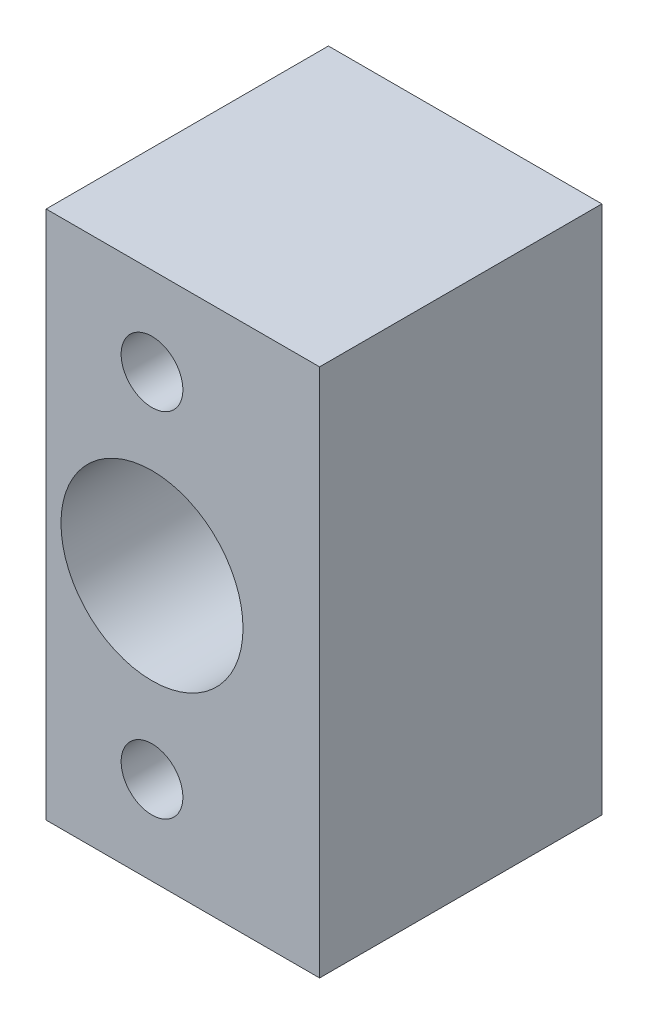
from build123d import *

# Parameters (mm, degrees)
SKETCH1_W               = 19
SKETCH1_H               = 30
BOSS_EXTRUDE1_DEPTH     = 18
SKETCH2_R               = 5.159375
CUT_EXTRUDE1_DEPTH      = 11.5
SKETCH4_R               = 4.8
CUT_EXTRUDE3_DEPTH      = 0.5
CUT_EXTRUDE4_DEPTH      = 22.430118992
CUT_EXTRUDE4_DEPTH_BACK = 8
SKETCH5_R               = 2.38125
CUT_EXTRUDE6_DEPTH      = 26.28339376
CUT_EXTRUDE6_DEPTH_BACK = 26.28339376
SKETCH11_W              = 15.5
SKETCH11_H              = 30
BOSS_EXTRUDE5_DEPTH     = 5
SKETCH12_R              = 4
CUT_EXTRUDE8_DEPTH      = 7.9
SKETCH13_R              = 1.75
CUT_EXTRUDE9_DEPTH      = 30.055980452
SKETCH15_W              = 15.5
SKETCH15_H              = 2
SKETCH15_H_2            = 5
CUT_EXTRUDE11_DEPTH     = 41
SKETCH17_R              = 5
CUT_EXTRUDE12_DEPTH     = 2
SKETCH20_R              = 3.81
CUT_EXTRUDE13_DEPTH     = 4


with BuildPart() as part:
    # Sketch1 → Boss-Extrude1 (new body)
    with BuildSketch(Plane.XY):
        Rectangle(SKETCH1_W, SKETCH1_H)
    extrude(amount=BOSS_EXTRUDE1_DEPTH)

    # Sketch2 → Cut-Extrude1 (cut)
    with BuildSketch(Plane.XY.offset(18)):
        Circle(SKETCH2_R)
    extrude(amount=-CUT_EXTRUDE1_DEPTH, mode=Mode.SUBTRACT)

    # Sketch4 → Cut-Extrude3 (cut)
    with BuildSketch(Plane.XY.offset(6.5)):
        Circle(SKETCH4_R)
    extrude(amount=-CUT_EXTRUDE3_DEPTH, mode=Mode.SUBTRACT)

    # Sketch5 → Cut-Extrude4 (cut, two sides: drawn at the far end of the back side and taken through both)
    with BuildSketch(Plane.XY.offset(6).offset(-CUT_EXTRUDE4_DEPTH_BACK)):
        Circle(SKETCH5_R)
    extrude(amount=CUT_EXTRUDE4_DEPTH + CUT_EXTRUDE4_DEPTH_BACK, mode=Mode.SUBTRACT)

    # Sketch6 → Cut-Extrude6 (cut, two sides: drawn at the far end of the back side and taken through both)
    with BuildSketch(Plane.XY.offset(-CUT_EXTRUDE6_DEPTH_BACK)):
        Polygon((-6, 92.53517602), (-6, 15), (-6, -15), (-6, -92.53517602), (-161.070352039, -92.53517602), (-161.070352039, 92.53517602), align=None)
    extrude(amount=CUT_EXTRUDE6_DEPTH + CUT_EXTRUDE6_DEPTH_BACK, mode=Mode.SUBTRACT)

    # Sketch11 → Boss-Extrude5 (add)
    with BuildSketch(Plane(origin=(0, 0, 0), x_dir=(-1, 0, 0), z_dir=(0, 0, -1))):
        with Locations((-1.75, 0)):
            Rectangle(SKETCH11_W, SKETCH11_H)
    extrude(amount=BOSS_EXTRUDE5_DEPTH)

    # Sketch12 → Cut-Extrude8 (cut)
    with BuildSketch(Plane(origin=(0, 0, -5), x_dir=(-1, 0, 0), z_dir=(0, 0, -1))):
        Circle(SKETCH12_R)
    extrude(amount=-CUT_EXTRUDE8_DEPTH, mode=Mode.SUBTRACT)

    # Sketch13 → Cut-Extrude9 (cut, through all)
    with BuildSketch(Plane(origin=(0, 0, -5), x_dir=(-1, 0, 0), z_dir=(0, 0, -1))):
        with Locations((0, -10)):
            Circle(SKETCH13_R)
        with Locations((0, 10)):
            Circle(SKETCH13_R)
    extrude(amount=-CUT_EXTRUDE9_DEPTH, mode=Mode.SUBTRACT)

    # Sketch15 → Cut-Extrude11 (cut)
    with BuildSketch(Plane.XZ.offset(15)):
        with Locations((1.75, 17)):
            Rectangle(SKETCH15_W, SKETCH15_H)
        with Locations((1.75, -2.5)):
            Rectangle(SKETCH15_W, SKETCH15_H_2)
    extrude(amount=-CUT_EXTRUDE11_DEPTH, mode=Mode.SUBTRACT)

    # Sketch17 → Cut-Extrude12 (cut)
    with BuildSketch(Plane(origin=(-6, -15, 0), x_dir=(0.9099076659797816, -0.36600957152300884, -0.19520510481227138), z_dir=(0.4148108477260767, 0.8028597052762778, 0.42819184281401484))):
        Circle(SKETCH17_R)
    extrude(amount=CUT_EXTRUDE12_DEPTH, mode=Mode.SUBTRACT)

    # Sketch20 → Cut-Extrude13 (cut)
    with BuildSketch(Plane(origin=(0, 0, 0), x_dir=(-1, 0, 0), z_dir=(0, 0, -1))):
        with Locations((0, 10)):
            Circle(SKETCH20_R)
        with Locations((0, -10)):
            Circle(SKETCH20_R)
    extrude(amount=-CUT_EXTRUDE13_DEPTH, mode=Mode.SUBTRACT)


solid = part.part
